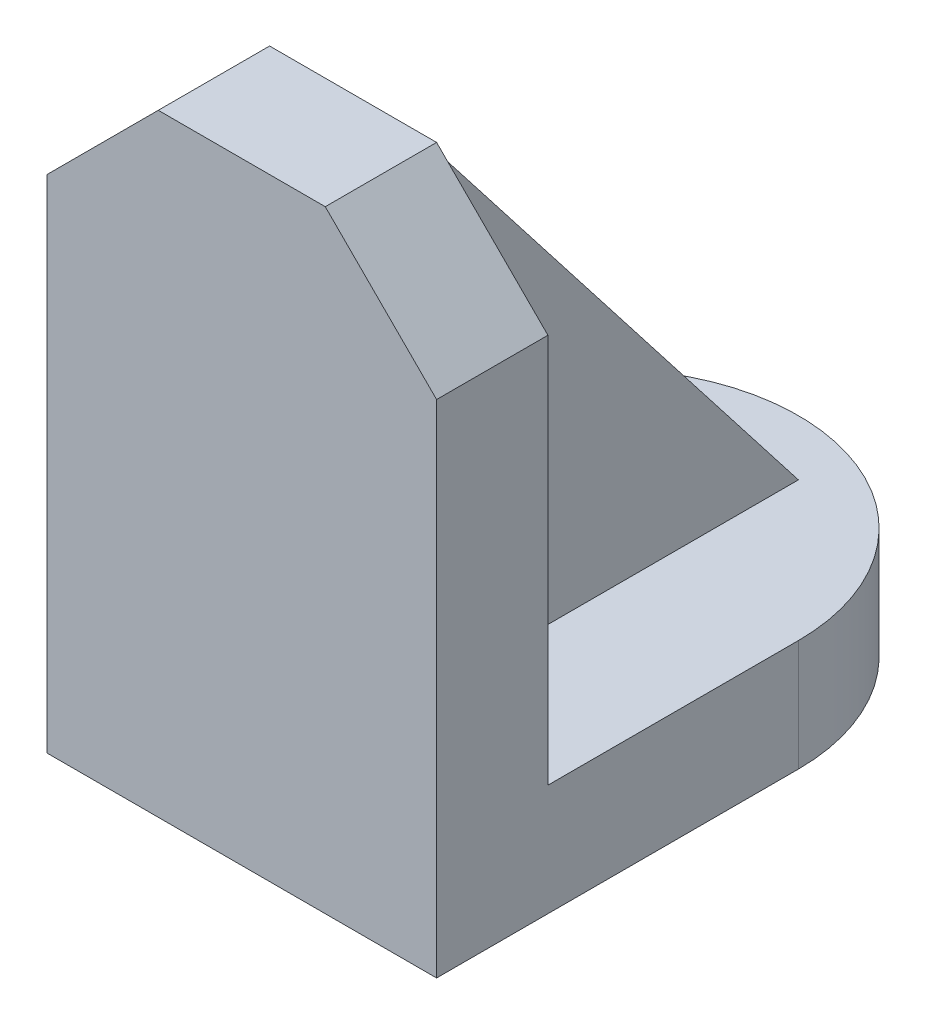
from build123d import *

# Parameters (mm, degrees)
BOSS_EXTRUDE3_DEPTH = 12
SKETCH4_W           = 42
SKETCH4_H           = 12
BOSS_EXTRUDE4_DEPTH = 54
CHAMFER1_SIZE       = 12
CHAMFER2_SIZE       = 12
BOSS_EXTRUDE6_DEPTH = 12


with BuildPart() as part:
    # Sketch1 → Boss-Extrude3 (new body)
    with BuildSketch(Plane(origin=(0, 0, 0), x_dir=(1, 0, 0), z_dir=(0, 1, 0))):
        with BuildLine():
            Line((-21, 19.5), (-21, -19.5))
            Line((-21, -19.5), (21, -19.5))
            Line((21, -19.5), (21, 19.5))
            ThreePointArc((21, 19.5), (0, 40.5), (-21, 19.5))
        make_face()
    extrude(amount=BOSS_EXTRUDE3_DEPTH)

    # Sketch4 → Boss-Extrude4 (add)
    with BuildSketch(Plane(origin=(0, 12, 0), x_dir=(1, 0, 0), z_dir=(0, 1, 0))):
        with Locations((0, -13.5)):
            Rectangle(SKETCH4_W, SKETCH4_H)
    extrude(amount=BOSS_EXTRUDE4_DEPTH)

    # Chamfer1
    chamfer1_edges = [part.edges().sort_by_distance(p)[0] for p in [
        (-21, 66, 13.5),
    ]]
    chamfer(chamfer1_edges, length=CHAMFER1_SIZE)

    # Chamfer2
    chamfer2_edges = [part.edges().sort_by_distance(p)[0] for p in [
        (21, 66, 13.5),
    ]]
    chamfer(chamfer2_edges, length=CHAMFER2_SIZE)

    # Sketch7 → Boss-Extrude6 (add)
    with BuildSketch(Plane.ZY.offset(6)):
        Polygon((7.5, 12), (-34.5, 12), (7.5, 66), align=None)
    extrude(amount=-BOSS_EXTRUDE6_DEPTH)


solid = part.part
